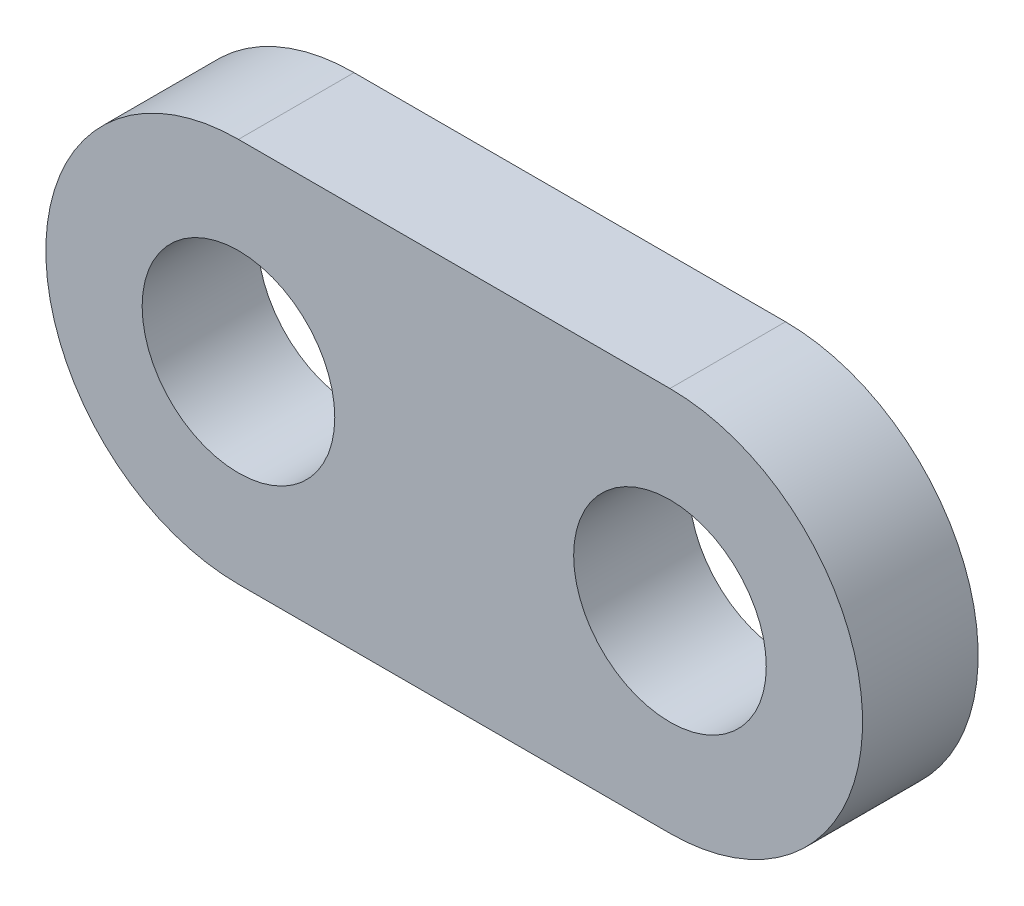
from build123d import *

# Parameters (mm, degrees)
CROQUIS1_R              = 5
SALIENTE_EXTRUIR1_DEPTH = 6


with BuildPart() as part:
    # Croquis1 → Saliente-Extruir1 (new body)
    with BuildSketch(Plane.XY):
        with BuildLine():
            Line((-11.224233903, 10), (11.175766097, 10))
            ThreePointArc((11.175766097, 10), (21.175766097, 0), (11.175766097, -10))
            Line((11.175766097, -10), (-11.224233903, -10))
            ThreePointArc((-11.224233903, -10), (-21.224233903, 0), (-11.224233903, 10))
        make_face()
        with Locations((-11.224233903, 0)):
            Circle(CROQUIS1_R, mode=Mode.SUBTRACT)
        with Locations((11.175766097, 0)):
            Circle(CROQUIS1_R, mode=Mode.SUBTRACT)
    extrude(amount=SALIENTE_EXTRUIR1_DEPTH)


solid = part.part
